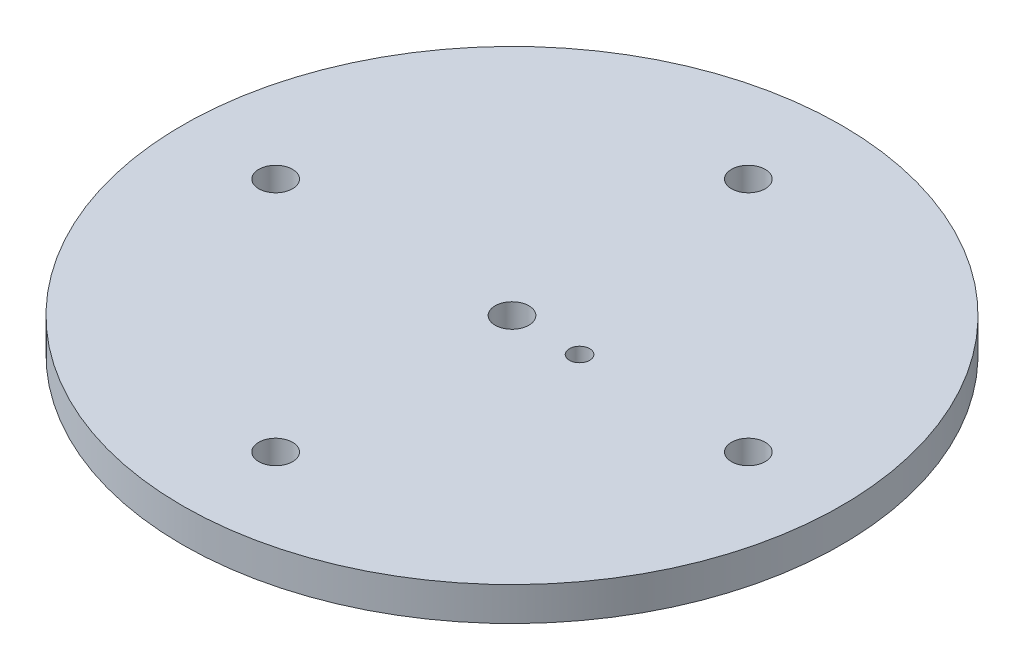
from build123d import *

# Parameters (mm, degrees)
SKETCH1_R                       = 61.976
BOSS_EXTRUDE1_DEPTH             = 6.35
F_1_4_0_25_DIAMETER_HOLE1_D     = 6.35
F_1_4_0_25_DIAMETER_HOLE1_DEPTH = 44.958
SKETCH4_R                       = 1.905
CUT_EXTRUDE1_DEPTH              = 7.35


with BuildPart() as part:
    # Sketch1 → Boss-Extrude1 (new body)
    with BuildSketch(Plane(origin=(0, 0, 0), x_dir=(1, 0, 0), z_dir=(0, 1, 0))):
        Circle(SKETCH1_R)
    extrude(amount=BOSS_EXTRUDE1_DEPTH)

    # 1/4 (0.25) Diameter Hole1
    with Locations(Plane(origin=(0, 6.35, 0), x_dir=(1, 0, 0), z_dir=(0, 1, 0))):
        with Locations((0, 44.45), (44.45, 0), (0, -44.45), (-44.45, 0), (0, 0)):
            Hole(F_1_4_0_25_DIAMETER_HOLE1_D / 2, depth=F_1_4_0_25_DIAMETER_HOLE1_DEPTH)

    # Sketch4 → Cut-Extrude1 (cut, through all)
    with BuildSketch(Plane(origin=(0, 6.35, 0), x_dir=(1, 0, 0), z_dir=(0, 1, 0))):
        with Locations((12.7, 0)):
            Circle(SKETCH4_R)
    extrude(amount=-CUT_EXTRUDE1_DEPTH, mode=Mode.SUBTRACT)


solid = part.part
